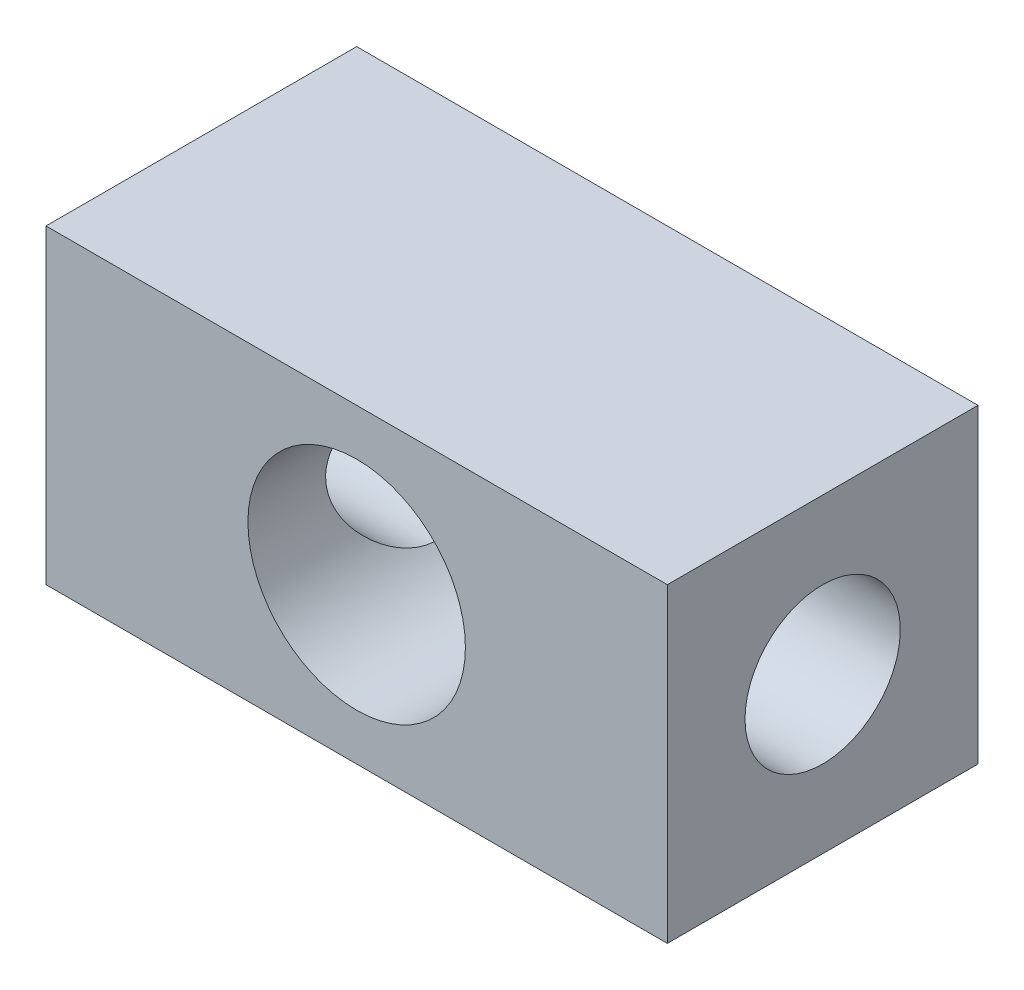
from build123d import *

# Parameters (mm, degrees)
SKETCH_1_W          = 40
SKETCH_1_H          = 20
SKETCH_1_R          = 7
EXTRUDE_1_DEPTH     = 20
SKETCH_2_R          = 5
CUT_EXTRUDE_1_DEPTH = 41


with BuildPart() as part:
    # 草图1 → 凸台-拉伸1 (new body)
    with BuildSketch(Plane.XY):
        Rectangle(SKETCH_1_W, SKETCH_1_H)
        Circle(SKETCH_1_R, mode=Mode.SUBTRACT)
    extrude(amount=EXTRUDE_1_DEPTH)

    # 草图2 → 切除-拉伸1 (cut, through all)
    with BuildSketch(Plane.ZY.offset(20)):
        with Locations((10, 0)):
            Circle(SKETCH_2_R)
    extrude(amount=-CUT_EXTRUDE_1_DEPTH, mode=Mode.SUBTRACT)


solid = part.part
